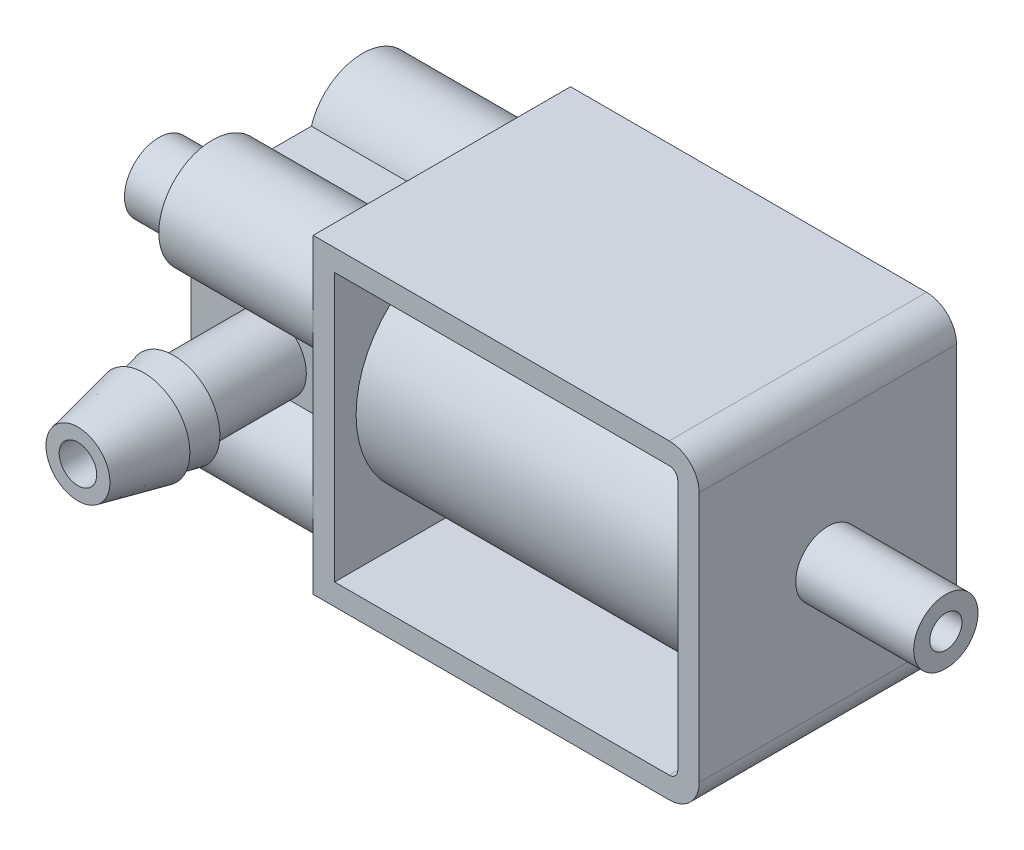
from build123d import *

# Parameters (mm, degrees)
BOSS_EXTRUDE1_DEPTH   = 12
SKETCH2_R             = 1.5
SKETCH2_R_2           = 0.75
BOSS_EXTRUDE2_DEPTH   = 5.5
BOSS_EXTRUDE3_REACH   = 28.511
SKETCH3_R             = 5
SKETCH4_R             = 1.85
BOSS_EXTRUDE4_DEPTH   = 7.2
SKETCH4_6_R           = 1.85
SKETCH4_6_R_2         = 1.1
BOSS_EXTRUDE6_DEPTH   = 3.7
BOSS_EXTRUDE6_2_DEPTH = 3.7
BOSS_EXTRUDE6_3_DEPTH = 3.7
BOSS_EXTRUDE6_4_DEPTH = 3.7
SKETCH5_R             = 1.6
SKETCH5_R_2           = 0.57
BOSS_EXTRUDE7_DEPTH   = 6
BOSS_EXTRUDE8_REACH   = 29.756


with BuildPart() as part:
    # Sketch1 → Boss-Extrude1 (new body)
    with BuildSketch(Plane.XY):
        with BuildLine():
            Line((9, -5.85), (9, 5.85))
            ThreePointArc((9, 5.85), (8.589949, 6.839949), (7.6, 7.25))
            Line((7.6, 7.25), (-9, 7.25))
            Line((-9, 7.25), (-9, -7.25))
            Line((-9, -7.25), (7.6, -7.25))
            ThreePointArc((7.6, -7.25), (8.589949, -6.839949), (9, -5.85))
        make_face()
        with BuildLine():
            Line((-8, -6.25), (7.6, -6.25))
            ThreePointArc((7.6, -6.25), (7.882843, -6.132843), (8, -5.85))
            Line((8, -5.85), (8, 5.85))
            ThreePointArc((8, 5.85), (7.882843, 6.132843), (7.6, 6.25))
            Line((7.6, 6.25), (-8, 6.25))
            Line((-8, 6.25), (-8, -6.25))
        make_face(mode=Mode.SUBTRACT)
    extrude(amount=BOSS_EXTRUDE1_DEPTH)

    # Sketch2 → Boss-Extrude2 (add)
    with BuildSketch(Plane(origin=(9, 0, 0), x_dir=(0, 0, -1), z_dir=(1, 0, 0))):
        with Locations(Location((-6, 0, 0), (0, 0, 180))):
            Circle(SKETCH2_R)
        with Locations((-6, 0)):
            Circle(SKETCH2_R_2, mode=Mode.SUBTRACT)
    extrude(amount=BOSS_EXTRUDE2_DEPTH)

    # Sketch3 → Boss-Extrude3 (add, up to next)
    with BuildSketch(Plane(origin=(-8, 0, 0), x_dir=(0, 0, -1), z_dir=(1, 0, 0)), mode=Mode.PRIVATE) as boss_extrude3_sk1:
        with Locations(Location((-6, 0, 0), (0, 0, 180))):
            Circle(SKETCH3_R)
    boss_extrude3_tool1 = extrude(boss_extrude3_sk1.sketch, amount=BOSS_EXTRUDE3_REACH, mode=Mode.PRIVATE) - part.part
    add(boss_extrude3_tool1.solids().sort_by_distance((-8, 0, 6))[0])


with BuildPart() as body_2:
    # Sketch4 → Boss-Extrude4 (new body)
    with BuildSketch(Plane.ZY.offset(9)):
        with BuildLine():
            ThreePointArc((1.5, -1.458712), (0.829129, -5.609621), (4.884848, -4.5))
            Line((4.884848, -4.5), (7.115152, -4.5))
            ThreePointArc((7.115152, -4.5), (11.170871, -5.609621), (10.5, -1.458712))
            Line((10.5, -1.458712), (10.5, 1.458712))
            ThreePointArc((10.5, 1.458712), (11.170871, 5.609621), (7.115152, 4.5))
            Line((7.115152, 4.5), (4.884848, 4.5))
            ThreePointArc((4.884848, 4.5), (0.829129, 5.609621), (1.5, 1.458712))
            Line((1.5, 1.458712), (1.5, -1.458712))
        make_face()
        with Locations((2.5, -3.75)):
            Circle(SKETCH4_R, mode=Mode.SUBTRACT)
        with Locations((9.5, 3.75)):
            Circle(SKETCH4_R, mode=Mode.SUBTRACT)
        with Locations((9.5, -3.75)):
            Circle(SKETCH4_R, mode=Mode.SUBTRACT)
        with Locations((2.5, 3.75)):
            Circle(SKETCH4_R, mode=Mode.SUBTRACT)
    extrude(amount=BOSS_EXTRUDE4_DEPTH)


with BuildPart() as body_3:
    # Sketch4_6 → Boss-Extrude6 (new body)
    with BuildSketch(Plane.ZY.offset(9)):
        with Locations((2.5, 3.75)):
            Circle(SKETCH4_6_R)
        with Locations((2.5, 3.75)):
            Circle(SKETCH4_6_R_2, mode=Mode.SUBTRACT)
    extrude(amount=BOSS_EXTRUDE6_DEPTH)


with BuildPart() as body_4:
    # Sketch4_6 → Boss-Extrude6 2 (new body)
    with BuildSketch(Plane.ZY.offset(9)):
        with Locations((9.5, 3.75)):
            Circle(SKETCH4_6_R)
        with Locations((9.5, 3.75)):
            Circle(SKETCH4_6_R_2, mode=Mode.SUBTRACT)
    extrude(amount=BOSS_EXTRUDE6_2_DEPTH)


with BuildPart() as body_5:
    # Sketch4_6 → Boss-Extrude6 3 (new body)
    with BuildSketch(Plane.ZY.offset(9)):
        with Locations((9.5, -3.75)):
            Circle(SKETCH4_6_R)
        with Locations((9.5, -3.75)):
            Circle(SKETCH4_6_R_2, mode=Mode.SUBTRACT)
    extrude(amount=BOSS_EXTRUDE6_3_DEPTH)


with BuildPart() as body_6:
    # Sketch4_6 → Boss-Extrude6 4 (new body)
    with BuildSketch(Plane.ZY.offset(9)):
        with Locations((2.5, -3.75)):
            Circle(SKETCH4_6_R)
        with Locations((2.5, -3.75)):
            Circle(SKETCH4_6_R_2, mode=Mode.SUBTRACT)
    extrude(amount=BOSS_EXTRUDE6_4_DEPTH)


with BuildPart() as body_2_1:
    add(body_2.part)

    # Combine1: union body 3, body 4, body 5, body 6
    add(body_3.part)
    add(body_4.part)
    add(body_5.part)
    add(body_6.part)

    # Sketch5 → Boss-Extrude7 (add)
    with BuildSketch(Plane.ZY.offset(16.2)):
        with Locations((6, 0)):
            Circle(SKETCH5_R)
        with Locations((6, 0)):
            Circle(SKETCH5_R_2, mode=Mode.SUBTRACT)
    extrude(amount=BOSS_EXTRUDE7_DEPTH)

    # Sketch6 → Boss-Extrude8 (add, up to next)
    with BuildSketch(Plane.XY.offset(15), mode=Mode.PRIVATE) as boss_extrude8_sk1:
        with BuildLine():
            ThreePointArc((-13.333402, 1.458712), (-14.18, 0), (-13.333402, -1.458712))
            Line((-13.333402, -1.458712), (-12.5, -1.458712))
            Line((-12.5, -1.458712), (-12.5, -0.875))
            ThreePointArc((-12.5, -0.875), (-13.375, 0), (-12.5, 0.875))
            Line((-12.5, 0.875), (-12.5, 1.458712))
            Line((-12.5, 1.458712), (-13.333402, 1.458712))
        make_face()
    boss_extrude8_tool1 = extrude(boss_extrude8_sk1.sketch, amount=-BOSS_EXTRUDE8_REACH, mode=Mode.PRIVATE) - body_2_1.part
    # Sketch6 → Boss-Extrude8 (add, up to next)
    with BuildSketch(Plane.XY.offset(15), mode=Mode.PRIVATE) as boss_extrude8_sk2:
        with BuildLine():
            Line((-12.5, -0.875), (-12.5, -1.458712))
            Line((-12.5, -1.458712), (-11.666598, -1.458712))
            ThreePointArc((-11.666598, -1.458712), (-11.046983, -0.843293), (-10.82, 0))
            ThreePointArc((-10.82, 0), (-11.046983, 0.843293), (-11.666598, 1.458712))
            Line((-11.666598, 1.458712), (-12.5, 1.458712))
            Line((-12.5, 1.458712), (-12.5, 0.875))
            ThreePointArc((-12.5, 0.875), (-11.881282, 0.618718), (-11.625, 0))
            ThreePointArc((-11.625, 0), (-11.881282, -0.618718), (-12.5, -0.875))
        make_face()
    boss_extrude8_tool2 = extrude(boss_extrude8_sk2.sketch, amount=-BOSS_EXTRUDE8_REACH, mode=Mode.PRIVATE) - body_2_1.part
    # Sketch6 → Boss-Extrude8 (add, up to next)
    with BuildSketch(Plane.XY.offset(15), mode=Mode.PRIVATE) as boss_extrude8_sk3:
        with BuildLine():
            ThreePointArc((-13.333402, 1.458712), (-14.18, 0), (-13.333402, -1.458712))
            Line((-13.333402, -1.458712), (-12.5, -1.458712))
            Line((-12.5, -1.458712), (-12.5, -0.875))
            ThreePointArc((-12.5, -0.875), (-13.375, 0), (-12.5, 0.875))
            Line((-12.5, 0.875), (-12.5, 1.458712))
            Line((-12.5, 1.458712), (-13.333402, 1.458712))
        make_face()
    boss_extrude8_tool3 = extrude(boss_extrude8_sk3.sketch, amount=-BOSS_EXTRUDE8_REACH, mode=Mode.PRIVATE) - body_2_1.part
    # Sketch6 → Boss-Extrude8 (add, up to next)
    with BuildSketch(Plane.XY.offset(15), mode=Mode.PRIVATE) as boss_extrude8_sk4:
        with BuildLine():
            Line((-12.5, -0.875), (-12.5, -1.458712))
            Line((-12.5, -1.458712), (-11.666598, -1.458712))
            ThreePointArc((-11.666598, -1.458712), (-11.046983, -0.843293), (-10.82, 0))
            ThreePointArc((-10.82, 0), (-11.046983, 0.843293), (-11.666598, 1.458712))
            Line((-11.666598, 1.458712), (-12.5, 1.458712))
            Line((-12.5, 1.458712), (-12.5, 0.875))
            ThreePointArc((-12.5, 0.875), (-11.881282, 0.618718), (-11.625, 0))
            ThreePointArc((-11.625, 0), (-11.881282, -0.618718), (-12.5, -0.875))
        make_face()
    boss_extrude8_tool4 = extrude(boss_extrude8_sk4.sketch, amount=-BOSS_EXTRUDE8_REACH, mode=Mode.PRIVATE) - body_2_1.part
    # Sketch6 → Boss-Extrude8 (add, up to next)
    with BuildSketch(Plane.XY.offset(15), mode=Mode.PRIVATE) as boss_extrude8_sk5:
        with BuildLine():
            ThreePointArc((-11.666598, 1.458712), (-12.5, 1.68), (-13.333402, 1.458712))
            Line((-13.333402, 1.458712), (-12.5, 1.458712))
            Line((-12.5, 1.458712), (-11.666598, 1.458712))
        make_face()
    boss_extrude8_tool5 = extrude(boss_extrude8_sk5.sketch, amount=-BOSS_EXTRUDE8_REACH, mode=Mode.PRIVATE) - body_2_1.part
    # Sketch6 → Boss-Extrude8 (add, up to next)
    with BuildSketch(Plane.XY.offset(15), mode=Mode.PRIVATE) as boss_extrude8_sk6:
        with BuildLine():
            Line((-12.5, -1.458712), (-13.333402, -1.458712))
            ThreePointArc((-13.333402, -1.458712), (-12.5, -1.68), (-11.666598, -1.458712))
            Line((-11.666598, -1.458712), (-12.5, -1.458712))
        make_face()
    boss_extrude8_tool6 = extrude(boss_extrude8_sk6.sketch, amount=-BOSS_EXTRUDE8_REACH, mode=Mode.PRIVATE) - body_2_1.part
    add(boss_extrude8_tool1.solids().sort_by_distance((-13.384074, 0, 15))[0])
    add(boss_extrude8_tool2.solids().sort_by_distance((-11.615926, 0, 15))[0])
    add(boss_extrude8_tool3.solids().sort_by_distance((-13.384074, 0, 15))[0])
    add(boss_extrude8_tool4.solids().sort_by_distance((-11.615926, 0, 15))[0])
    add(boss_extrude8_tool5.solids().sort_by_distance((-12.5, 1.547747, 15))[0])
    add(boss_extrude8_tool6.solids().sort_by_distance((-12.5, -1.547747, 15))[0])

    # Sketch8 → Revolve1 (revolve)
    with BuildSketch(Plane.ZY.offset(12.5), mode=Mode.PRIVATE) as revolve1_sk:
        Polygon((15, 1.68), (15, 0.875), (19.47, 0.875), (19.47, 1.492143), (16.4, 2.15), (16.4, 1.85), (15, 2.15), align=None)
    revolve(revolve1_sk.sketch.rotate(Axis((-12.5, 0, 15), (0, 0, 1)), 270), axis=Axis((-12.5, 0, 15), (0, 0, 1)))


solid = Compound([part.part, body_2_1.part])
